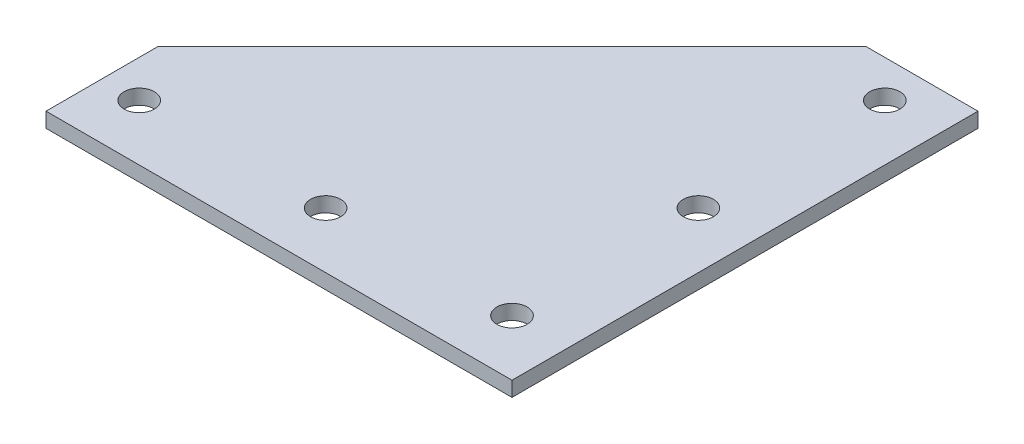
from build123d import *

# Parameters (mm, degrees)
SKETCH1_R           = 4.05
BOSS_EXTRUDE1_DEPTH = 4


with BuildPart() as part:
    # Sketch1 → Boss-Extrude1 (new body)
    with BuildSketch(Plane(origin=(0, 0, 0), x_dir=(1, 0, 0), z_dir=(0, 1, 0))):
        Polygon((15, -15), (-110, -15), (-110, 15), (-15, 110), (15, 110), align=None)
        with Locations((-100, 0)):
            Circle(SKETCH1_R, mode=Mode.SUBTRACT)
        with Locations((-50, 0)):
            Circle(SKETCH1_R, mode=Mode.SUBTRACT)
        Circle(SKETCH1_R, mode=Mode.SUBTRACT)
        with Locations((0, 100)):
            Circle(SKETCH1_R, mode=Mode.SUBTRACT)
        with Locations((0, 50)):
            Circle(SKETCH1_R, mode=Mode.SUBTRACT)
    extrude(amount=BOSS_EXTRUDE1_DEPTH)


solid = part.part
